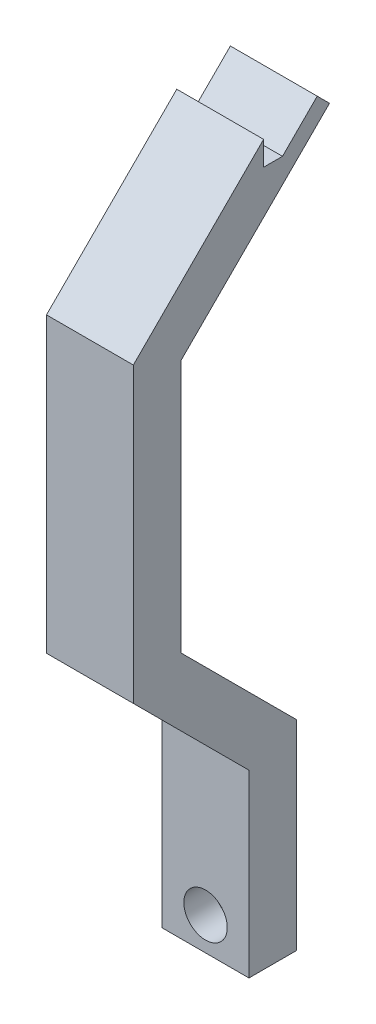
from build123d import *

# Parameters (mm, degrees)
ESTRUSIONE_ESTRUSIONE1_DEPTH = 5
SCHIZZO2_R                   = 1.625
TAGLIO_ESTRUSIONE1_DEPTH     = 10.274243706
SCHIZZO3_R                   = 2.5
TAGLIO_ESTRUSIONE2_DEPTH     = 3.5


with BuildPart() as part:
    # Schizzo1 → Estrusione-Estrusione1 (new body, symmetric)
    with BuildSketch(Plane(origin=(0, 0, 0), x_dir=(0, 0, -1), z_dir=(1, 0, 0))):
        Polygon((-21.188457268, 88.94490566), (-26.688457268, 88.94490566), (-26.688457268, 109.666731067), (-40, 122.978273799), (-40, 156.723080253), (-25, 171.723080253), (-25, 168.94490566), (-22.828427125, 168.94490566), (-18.828427125, 172.94490566), (-17.414213562, 171.530692098), (-34.5, 154.44490566), (-34.5, 125.256448392), (-21.188457268, 111.94490566), align=None)
    extrude(amount=ESTRUSIONE_ESTRUSIONE1_DEPTH, both=True)

    # Schizzo2 → Taglio-Estrusione1 (cut, through all)
    with BuildSketch(Plane.XY.offset(26.688457268)):
        with Locations((0, 92.723474812)):
            Circle(SCHIZZO2_R)
    extrude(amount=-TAGLIO_ESTRUSIONE1_DEPTH, mode=Mode.SUBTRACT)

    # Schizzo3 → Taglio-Estrusione2 (cut)
    with BuildSketch(Plane.XY.offset(26.688457268)):
        with Locations((0, 92.723474812)):
            Circle(SCHIZZO3_R)
    extrude(amount=-TAGLIO_ESTRUSIONE2_DEPTH, mode=Mode.SUBTRACT)


solid = part.part
